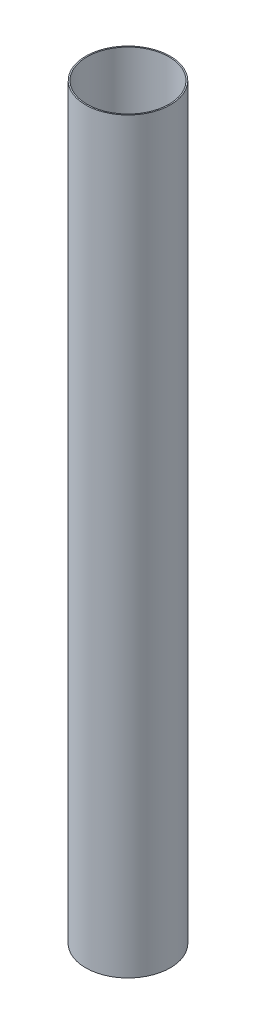
from build123d import *

# Parameters (mm, degrees)
SKETCH1_R           = 65.405
SKETCH1_R_2         = 63.5
BOSS_EXTRUDE1_DEPTH = 577.85


with BuildPart() as part:
    # Sketch1 → Boss-Extrude1 (new body, symmetric)
    with BuildSketch(Plane(origin=(0, 0, 0), x_dir=(1, 0, 0), z_dir=(0, 1, 0))):
        Circle(SKETCH1_R)
        Circle(SKETCH1_R_2, mode=Mode.SUBTRACT)
    extrude(amount=BOSS_EXTRUDE1_DEPTH, both=True)


solid = part.part
